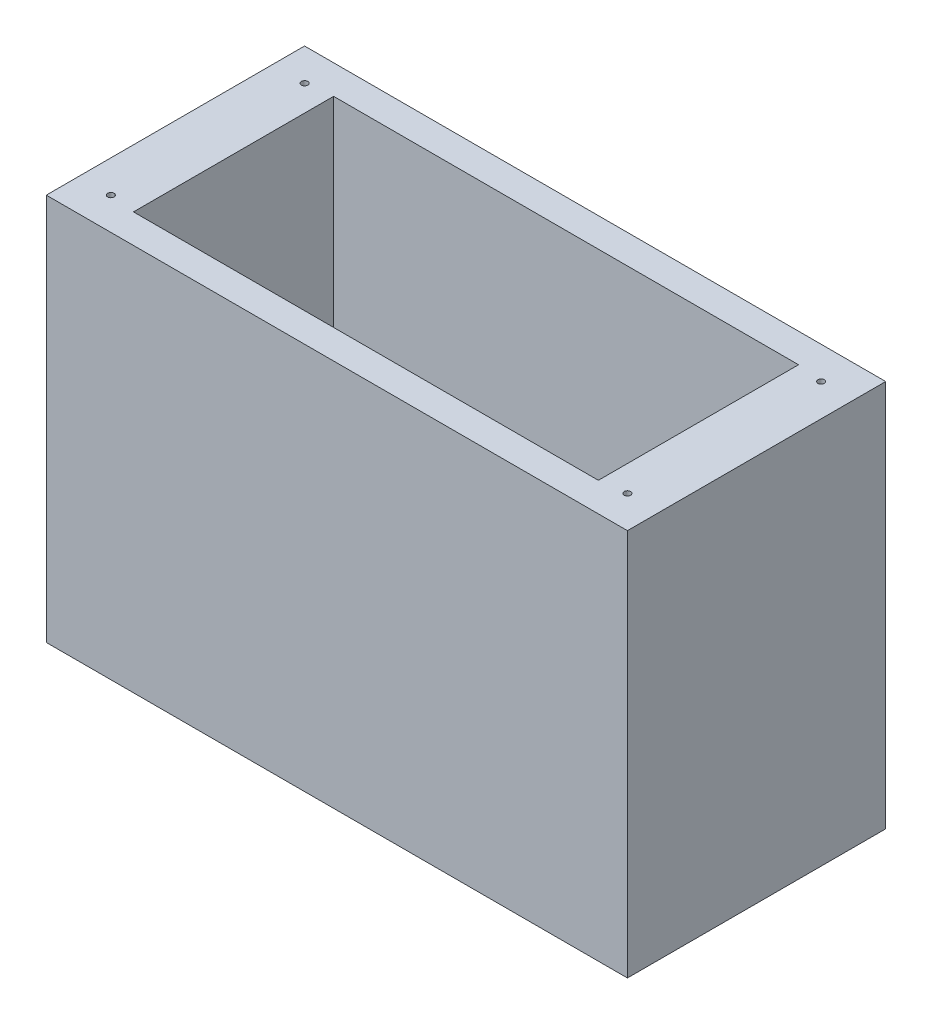
from build123d import *

# Parameters (mm, degrees)
SKETCH4_W           = 228.6
SKETCH4_H           = 101.6
BOSS_EXTRUDE2_DEPTH = 152.4
SKETCH5_W           = 182.88
SKETCH5_H           = 78.74
CUT_EXTRUDE3_DEPTH  = 139.7
SKETCH6_R           = 1.27
CUT_EXTRUDE4_DEPTH  = 153.4


with BuildPart() as part:
    # Sketch4 → Boss-Extrude2 (new body)
    with BuildSketch(Plane(origin=(0, 0, 0), x_dir=(1, 0, 0), z_dir=(0, 1, 0))):
        with Locations((114.3, 50.8)):
            Rectangle(SKETCH4_W, SKETCH4_H)
    extrude(amount=BOSS_EXTRUDE2_DEPTH)

    # Sketch5 → Cut-Extrude3 (cut)
    with BuildSketch(Plane(origin=(0, 152.4, 0), x_dir=(1, 0, 0), z_dir=(0, 1, 0))):
        with Locations((114.3, 50.8)):
            Rectangle(SKETCH5_W, SKETCH5_H)
    extrude(amount=-CUT_EXTRUDE3_DEPTH, mode=Mode.SUBTRACT)

    # Sketch6 → Cut-Extrude4 (cut, through all)
    with BuildSketch(Plane(origin=(0, 152.4, 0), x_dir=(1, 0, 0), z_dir=(0, 1, 0))):
        with Locations((12.7, 88.9)):
            Circle(SKETCH6_R)
        with Locations((215.9, 88.9)):
            Circle(SKETCH6_R)
        with Locations((12.7, 12.7)):
            Circle(SKETCH6_R)
        with Locations((215.9, 12.7)):
            Circle(SKETCH6_R)
    extrude(amount=-CUT_EXTRUDE4_DEPTH, mode=Mode.SUBTRACT)


solid = part.part
